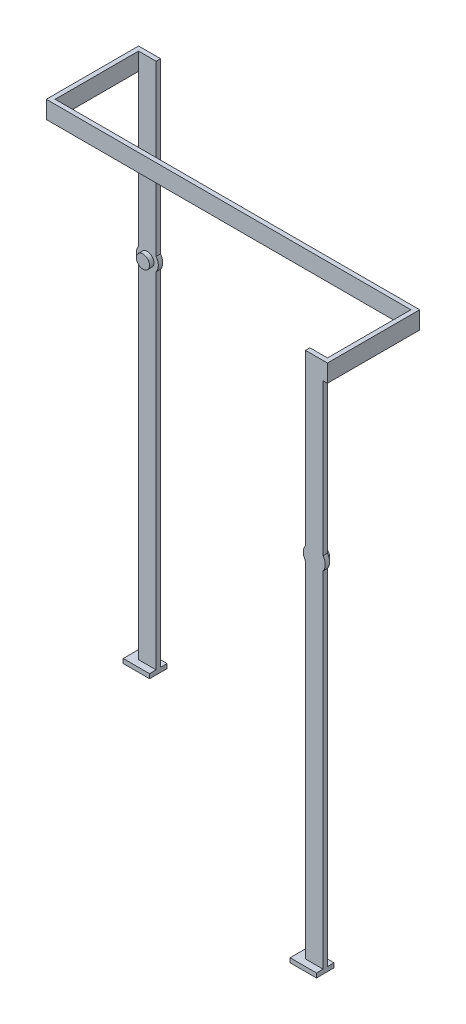
from build123d import *

# Parameters (mm, degrees)
EXTRUDE_2_DEPTH  = 1
SKETCH_2_R       = 1.5
EXTRUDE_3_DEPTH  = 1
EXTRUDE_4_DEPTH  = 1
SKETCH_4_R       = 1.5
EXTRUDE_5_DEPTH  = 1
SKETCH_5_W       = 82
SKETCH_5_H       = 4
EXTRUDE_6_DEPTH  = 0.5
SKETCH_6_W       = 21
SKETCH_6_H       = 4
EXTRUDE_7_DEPTH  = 1
SKETCH_7_W       = 21
SKETCH_7_H       = 4
EXTRUDE_8_DEPTH  = 1
SKETCH_8_W       = 6
SKETCH_8_H       = 4
EXTRUDE_9_DEPTH  = 1
SKETCH_9_W       = 6
SKETCH_9_H       = 4
EXTRUDE_10_DEPTH = 1


with BuildPart() as part:
    # 草图1 → 凸台-拉伸2 (new body)
    with BuildSketch(Plane.XY.offset(19.5)):
        with BuildLine():
            Line((56.648774872, 85.153357287), (60.648774872, 85.153357287))
            Line((60.648774872, 85.153357287), (60.648774872, 46.653357287))
            ThreePointArc((60.648774872, 46.653357287), (61.148774872, 45.153357287), (60.648774872, 43.653357287))
            Line((60.648774872, 43.653357287), (60.648774872, -34.846642713))
            Line((60.648774872, -34.846642713), (56.648774872, -34.846642713))
            Line((56.648774872, -34.846642713), (56.648774872, 43.653357287))
            ThreePointArc((56.648774872, 43.653357287), (56.148774872, 45.153357287), (56.648774872, 46.653357287))
            Line((56.648774872, 46.653357287), (56.648774872, 85.153357287))
        make_face()
    extrude(amount=EXTRUDE_2_DEPTH)

    # 草图2 → 凸台-拉伸3 (add)
    with BuildSketch(Plane(origin=(0, 0, 19.5), x_dir=(-1, 0, 0), z_dir=(0, 0, -1))):
        with Locations((-58.648774872, 45.153357287)):
            Circle(SKETCH_2_R)
    extrude(amount=EXTRUDE_3_DEPTH)



with BuildPart() as body_2:
    # 草图3 → 凸台-拉伸4 (new body)
    with BuildSketch(Plane(origin=(0, 0, -19.5), x_dir=(-1, 0, 0), z_dir=(0, 0, -1))):
        with BuildLine():
            Line((17.351225128, 43.653357287), (17.351225128, -34.846642713))
            Line((17.351225128, -34.846642713), (21.351225128, -34.846642713))
            Line((21.351225128, -34.846642713), (21.351225128, 43.653357287))
            ThreePointArc((21.351225128, 43.653357287), (21.851225128, 45.153357287), (21.351225128, 46.653357287))
            Line((21.351225128, 46.653357287), (21.351225128, 85.153357287))
            Line((21.351225128, 85.153357287), (17.351225128, 85.153357287))
            Line((17.351225128, 85.153357287), (17.351225128, 46.653357287))
            ThreePointArc((17.351225128, 46.653357287), (16.851225128, 45.153357287), (17.351225128, 43.653357287))
        make_face()
    extrude(amount=EXTRUDE_4_DEPTH)

    # 草图4 → 凸台-拉伸5 (add)
    with BuildSketch(Plane.XY.offset(-19.5)):
        with Locations((-19.351225128, 45.153357287)):
            Circle(SKETCH_4_R)
    extrude(amount=EXTRUDE_5_DEPTH)


with BuildPart() as body_3:
    # 草图5 → 凸台-拉伸6 (new body, symmetric)
    with BuildSketch(Plane.XY):
        with Locations((19.648774872, 83.153357287)):
            Rectangle(SKETCH_5_W, SKETCH_5_H)
    extrude(amount=EXTRUDE_6_DEPTH, both=True)


with BuildPart() as part_1:
    add(part.part)

    add(body_3.part)  # 凸台-拉伸7 merges body 3
    # 草图6 → 凸台-拉伸7 (add)
    with BuildSketch(Plane(origin=(60.648774872, 0, 0), x_dir=(0, 0, -1), z_dir=(1, 0, 0))):
        with Locations((-10, 83.153357287)):
            Rectangle(SKETCH_6_W, SKETCH_6_H)
    extrude(amount=EXTRUDE_7_DEPTH)


    add(body_2.part)  # 凸台-拉伸8 merges body 2
    # 草图7 → 凸台-拉伸8 (add)
    with BuildSketch(Plane.ZY.offset(21.351225128)):
        with Locations((-10, 83.153357287)):
            Rectangle(SKETCH_7_W, SKETCH_7_H)
    extrude(amount=EXTRUDE_8_DEPTH)

    # 草图8 → 凸台-拉伸9 (add)
    with BuildSketch(Plane.XZ.offset(34.846642713)):
        with Locations((-20.351225128, -20)):
            Rectangle(SKETCH_8_W, SKETCH_8_H)
    extrude(amount=EXTRUDE_9_DEPTH)

    # 草图9 → 凸台-拉伸10 (add)
    with BuildSketch(Plane.XZ.offset(34.846642713)):
        with Locations((57.648774872, 20)):
            Rectangle(SKETCH_9_W, SKETCH_9_H)
    extrude(amount=EXTRUDE_10_DEPTH)


solid = part_1.part
